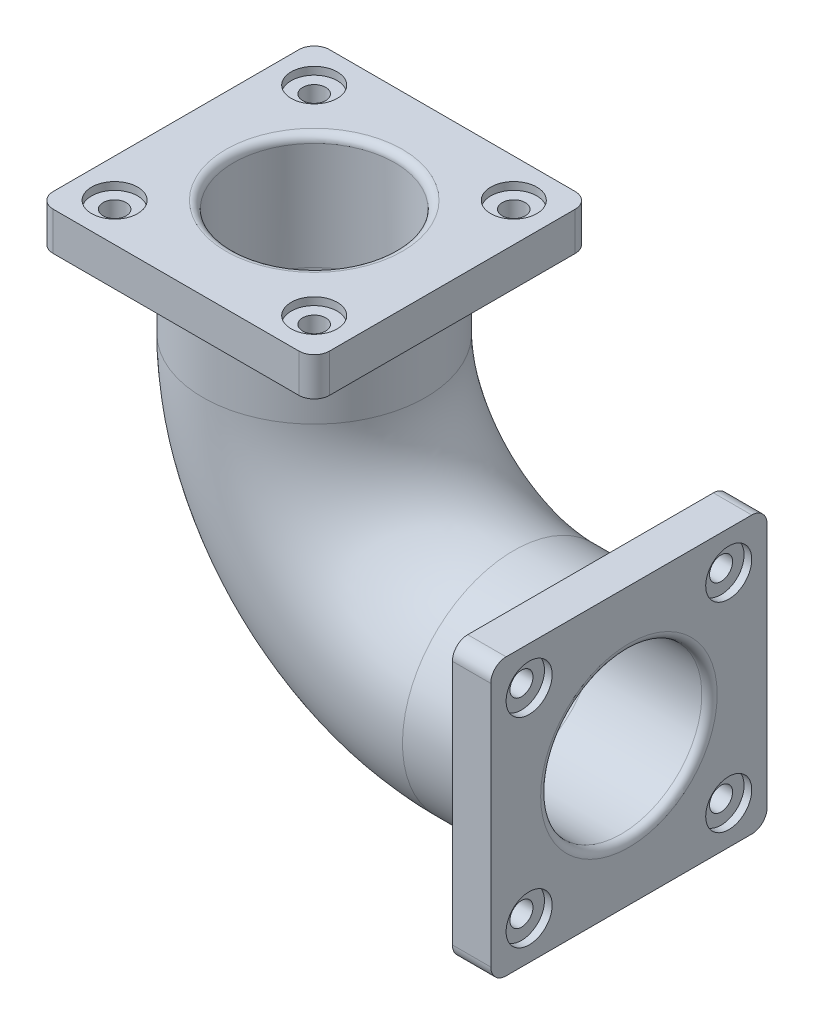
from build123d import *

# Parameters (mm, degrees)
SKETCH6_R            = 145
SKETCH6_R_2          = 105
SKETCH9_W            = 360
SKETCH9_H            = 360
SKETCH9_R            = 105
SKETCH9_R_2          = 15
BOSS_EXTRUDE1_DEPTH  = 50
FILLET1_R            = 20
SKETCH11_R           = 30
CUT_EXTRUDE1_DEPTH   = 10
FILLET2_R            = 10
FILLET1_OF_MIRROR4_R = 20
FILLET3_R            = 10
FILLET4_R            = 10


with BuildPart() as part:
    # Sweep1: sweep along a path in Sketch4
    with BuildLine(Plane.XY) as sweep1_path:
        Line((150, 0), (0, 0))
        ThreePointArc((0, 0), (-183.847763109, 76.152236891), (-260, 260))
        Line((-260, 260), (-260, 410))
    # Sketch6 → Sweep1 (sweep)
    with BuildSketch(Plane(origin=(0, 410, 0), x_dir=(1, 0, 0), z_dir=(0, 1, 0))):
        with Locations((-260, 0)):
            Circle(SKETCH6_R)
        with Locations((-260, 0)):
            Circle(SKETCH6_R_2, mode=Mode.SUBTRACT)
    sweep(path=sweep1_path.line)

    # Sketch9 → Boss-Extrude1 (add)
    with BuildSketch(Plane(origin=(150, 0, 0), x_dir=(0, 0, -1), z_dir=(1, 0, 0))):
        Rectangle(SKETCH9_W, SKETCH9_H)
        Circle(SKETCH9_R, mode=Mode.SUBTRACT)
        with Locations((-130, 130)):
            Circle(SKETCH9_R_2, mode=Mode.SUBTRACT)
        with Locations((130, 130)):
            Circle(SKETCH9_R_2, mode=Mode.SUBTRACT)
        with Locations((130, -130)):
            Circle(SKETCH9_R_2, mode=Mode.SUBTRACT)
        with Locations((-130, -130)):
            Circle(SKETCH9_R_2, mode=Mode.SUBTRACT)
    boss_extrude1 = extrude(amount=-BOSS_EXTRUDE1_DEPTH)

    # Fillet1
    fillet1_edges = [part.edges().sort_by_distance(p)[0] for p in [
        (125, -180, 180),
        (125, 180, 180),
        (125, 180, -180),
        (125, -180, -180),
    ]]
    fillet(fillet1_edges, radius=FILLET1_R)

    # Sketch11 → Cut-Extrude1 (cut)
    with BuildSketch(Plane(origin=(150, 0, 0), x_dir=(0, 0, -1), z_dir=(1, 0, 0))):
        with Locations((-130, 130)):
            Circle(SKETCH11_R)
        with Locations((130, 130)):
            Circle(SKETCH11_R)
        with Locations((130, -130)):
            Circle(SKETCH11_R)
        with Locations((-130, -130)):
            Circle(SKETCH11_R)
    cut_extrude1 = extrude(amount=-CUT_EXTRUDE1_DEPTH, mode=Mode.SUBTRACT)

    # Fillet2
    fillet2_edges = [part.edges().sort_by_distance(p)[0] for p in [
        (150, -105, 0),
    ]]
    fillet(fillet2_edges, radius=FILLET2_R)

    # Mirror4: Boss-Extrude1, Cut-Extrude1 across plane
    add(boss_extrude1.mirror(Plane(origin=(-130, 130, 0), x_dir=(0, 0, 1), z_dir=(0.707106781, -0.707106781, 0))))
    add(cut_extrude1.mirror(Plane(origin=(-130, 130, 0), x_dir=(0, 0, 1), z_dir=(0.707106781, -0.707106781, 0))), mode=Mode.SUBTRACT)

    # Fillet1 of Mirror4
    fillet1_of_mirror4_edges = [part.edges().sort_by_distance(p)[0] for p in [
        (-440, 385, 180),
        (-80, 385, 180),
        (-80, 385, -180),
        (-440, 385, -180),
    ]]
    fillet(fillet1_of_mirror4_edges, radius=FILLET1_OF_MIRROR4_R)

    # Fillet3
    fillet3_edges = [part.edges().sort_by_distance(p)[0] for p in [
        (-365, 410, 0),
    ]]
    fillet(fillet3_edges, radius=FILLET3_R)

    # Fillet4
    fillet4_edges = [part.edges().sort_by_distance(p)[0] for p in [
        (100, -145, 0),
        (-405, 360, 0),
    ]]
    fillet(fillet4_edges, radius=FILLET4_R)


solid = part.part
